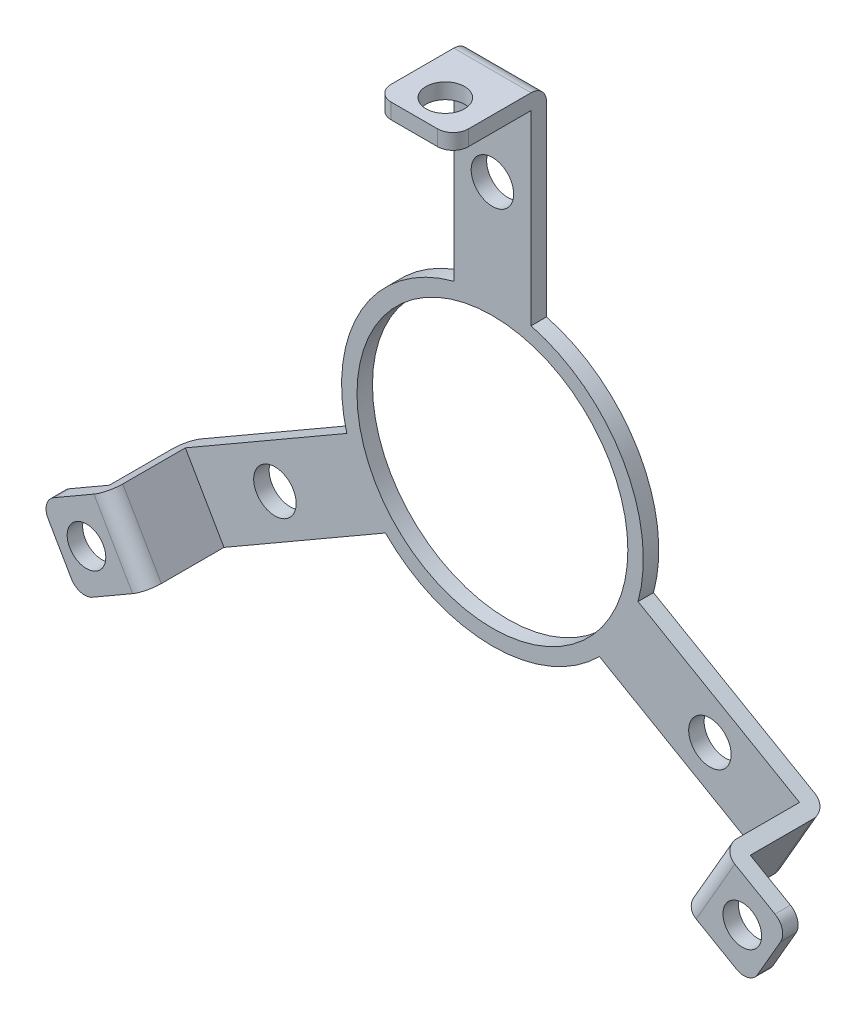
from build123d import *

# Parameters (mm, degrees)
SKETCH1_R             = 2.5
BOSS_EXTRUDE1_DEPTH   = 2
BOSS_EXTRUDE1_2_DEPTH = 2
BOSS_EXTRUDE2_DEPTH   = 10.1
SKETCH3_R             = 17.525
BOSS_EXTRUDE3_DEPTH   = 2
SKETCH4_R             = 2.75
CUT_EXTRUDE1_DEPTH    = 3
SKETCH2_3_W           = 10
SKETCH2_3_H           = 2
BOSS_EXTRUDE4_DEPTH   = 12.1
CUT_EXTRUDE2_REACH    = 77.098
SKETCH5_R             = 2.5
FILLET2_R             = 2
SKETCH6_R             = 2.75
CUT_EXTRUDE3_DEPTH    = 10


with BuildPart() as part:
    # Sketch1 → Boss-Extrude1 (new body)
    with BuildSketch(Plane.XY):
        with BuildLine():
            Line((-47.399346401, -23.901923789), (-44.399346401, -29.098076211))
            ThreePointArc((-44.399346401, -29.098076211), (-43.184933683, -30.029927864), (-41.667295593, -29.830127019))
            Line((-41.667295593, -29.830127019), (-36.47114317, -26.830127019))
            Line((-36.47114317, -26.830127019), (-41.47114317, -18.169872981))
            Line((-41.47114317, -18.169872981), (-46.667295593, -21.169872981))
            ThreePointArc((-46.667295593, -21.169872981), (-47.599147246, -22.384285698), (-47.399346401, -23.901923789))
        make_face()
        with Locations((-42.435244785, -24.5)):
            Circle(SKETCH1_R, mode=Mode.SUBTRACT)
    extrude(amount=BOSS_EXTRUDE1_DEPTH)



with BuildPart() as body_2:
    # Sketch1 → Boss-Extrude1 2 (new body)
    with BuildSketch(Plane.XY):
        with BuildLine():
            Line((41.667295593, -29.830127019), (36.47114317, -26.830127019))
            Line((36.47114317, -26.830127019), (41.47114317, -18.169872981))
            Line((41.47114317, -18.169872981), (46.667295593, -21.169872981))
            ThreePointArc((46.667295593, -21.169872981), (47.599147246, -22.384285698), (47.399346401, -23.901923789))
            Line((47.399346401, -23.901923789), (44.399346401, -29.098076211))
            ThreePointArc((44.399346401, -29.098076211), (43.184933683, -30.029927864), (41.667295593, -29.830127019))
        make_face()
        with Locations((42.435244785, -24.5)):
            Circle(SKETCH1_R, mode=Mode.SUBTRACT)
    extrude(amount=BOSS_EXTRUDE1_2_DEPTH)


with BuildPart() as part_1:
    add(part.part)

    add(body_2.part)  # Boss-Extrude2 merges body 2
    # Sketch2 → Boss-Extrude2 (add)
    with BuildSketch(Plane.XY.offset(2)):
        Polygon((41.47114317, -18.169872981), (36.47114317, -26.830127019), (34.739092363, -25.830127019), (39.739092363, -17.169872981), align=None)
        Polygon((-34.739092363, -25.830127019), (-39.739092363, -17.169872981), (-41.47114317, -18.169872981), (-36.47114317, -26.830127019), align=None)
    extrude(amount=-BOSS_EXTRUDE2_DEPTH)

    # Sketch3 → Boss-Extrude3 (add)
    with BuildSketch(Plane(origin=(0, 0, -8.1), x_dir=(-1, 0, 0), z_dir=(0, 0, -1))):
        with BuildLine():
            Line((-41.47114317, -18.169872981), (-36.47114317, -26.830127019))
            Line((-36.47114317, -26.830127019), (-13.845311828, -13.767097203))
            ThreePointArc((-13.845311828, -13.767097203), (0, -19.525), (13.845311828, -13.767097203))
            Line((13.845311828, -13.767097203), (36.47114317, -26.830127019))
            Line((36.47114317, -26.830127019), (41.47114317, -18.169872981))
            Line((41.47114317, -18.169872981), (18.845311828, -5.106843165))
            ThreePointArc((18.845311828, -5.106843165), (16.909146009, 9.7625), (5, 18.873940368))
            Line((5, 18.873940368), (5, 45))
            Line((5, 45), (-5, 45))
            Line((-5, 45), (-5, 18.873940368))
            ThreePointArc((-5, 18.873940368), (-16.909146009, 9.7625), (-18.845311828, -5.106843165))
            Line((-18.845311828, -5.106843165), (-41.47114317, -18.169872981))
        make_face()
        Circle(SKETCH3_R, mode=Mode.SUBTRACT)
    extrude(amount=BOSS_EXTRUDE3_DEPTH)

    # Sketch4 → Cut-Extrude1 (cut, through all)
    with BuildSketch(Plane.XY.offset(-8.1)):
        with Locations((0, 32.5)):
            Circle(SKETCH4_R)
    extrude(amount=-CUT_EXTRUDE1_DEPTH, mode=Mode.SUBTRACT)

    # Sketch2_3 → Boss-Extrude4 (add)
    with BuildSketch(Plane.XY.offset(2)):
        with Locations((0, 44)):
            Rectangle(SKETCH2_3_W, SKETCH2_3_H)
    extrude(amount=-BOSS_EXTRUDE4_DEPTH)

    # Sketch5 → Cut-Extrude2 (cut, up to next)
    with BuildSketch(Plane(origin=(0, 45, 0), x_dir=(1, 0, 0), z_dir=(0, 1, 0)), mode=Mode.PRIVATE) as cut_extrude2_sk1:
        with Locations((0, 2)):
            Circle(SKETCH5_R)
    cut_extrude2_tool1 = extrude(cut_extrude2_sk1.sketch, amount=-CUT_EXTRUDE2_REACH, mode=Mode.PRIVATE) & part_1.part
    add(cut_extrude2_tool1.solids().sort_by_distance((0, 45, -2))[0], mode=Mode.SUBTRACT)

    # Fillet2
    fillet2_edges = [part_1.edges().sort_by_distance(p)[0] for p in [
        (-37.239092363, -21.5, 2),
        (38.97114317, -22.5, -10.1),
        (-38.97114317, -22.5, -10.1),
        (0, 45, -10.1),
        (37.239092363, -21.5, 2),
        (5, 44, 2),
        (-5, 44, 2),
    ]]
    fillet(fillet2_edges, radius=FILLET2_R)

    # Sketch6 → Cut-Extrude3 (cut)
    with BuildSketch(Plane.XY.offset(-8.1)):
        with Locations((0, 32.5)):
            Circle(SKETCH6_R)
        with Locations((28.145825623, -16.25)):
            Circle(SKETCH6_R)
        with Locations((-28.145825623, -16.25)):
            Circle(SKETCH6_R)
    extrude(amount=-CUT_EXTRUDE3_DEPTH, mode=Mode.SUBTRACT)


solid = part_1.part
